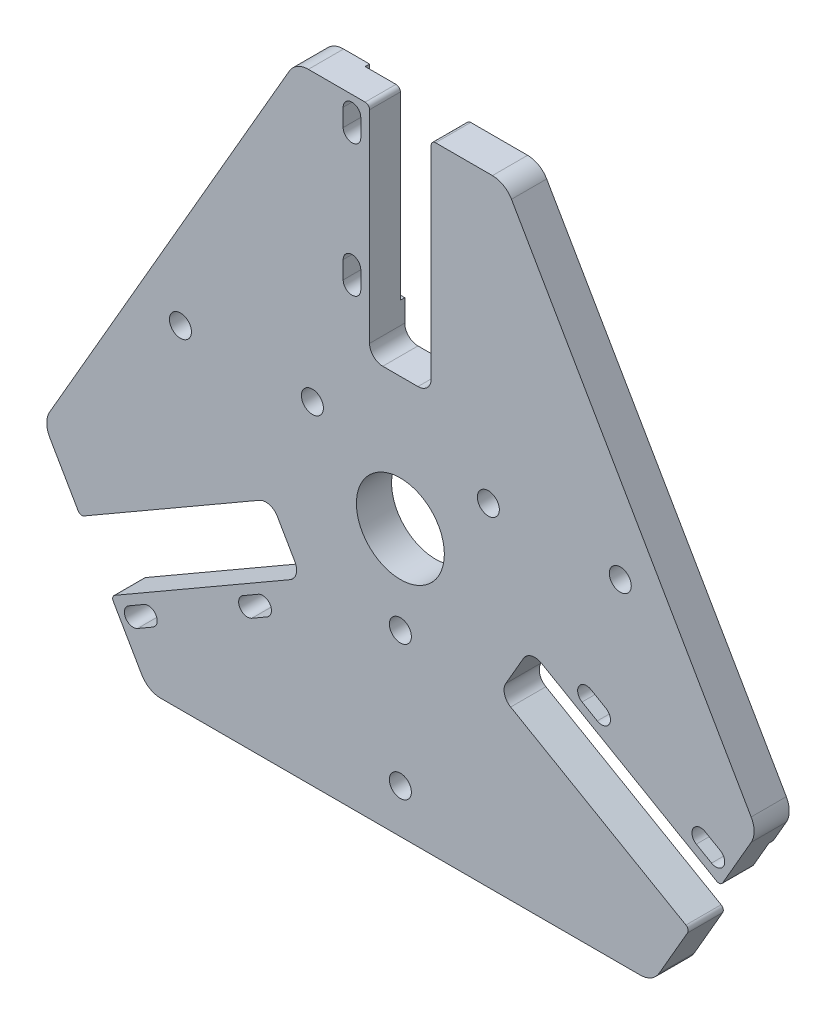
from build123d import *

# Parameters (mm, degrees)
BOSS_EXTRUDE1_DEPTH = 8
SKETCH5_R           = 2.5
SKETCH5_R_2         = 10
CUT_EXTRUDE26_DEPTH = 9
FILLET2_R           = 1
FILLET3_R           = 1
CUT_EXTRUDE27_DEPTH = 1
FILLET4_R           = 1


with BuildPart() as part:
    # Sketch3 → Boss-Extrude1 (new body)
    with BuildSketch(Plane.XY):
        with BuildLine():
            Line((69.282032303, -40), (0, 0))
            Line((0, 0), (-69.282032302, -40))
            Line((-69.282032302, -40), (-58.819418743, -58.121778265))
            ThreePointArc((-58.819418743, -58.121778265), (-56.989291724, -59.951905284), (-54.489291724, -60.621778265))
            Line((-54.489291724, -60.621778265), (54.489291724, -60.621778265))
            ThreePointArc((54.489291724, -60.621778265), (56.989291724, -59.951905284), (58.819418743, -58.121778265))
            Line((58.819418743, -58.121778265), (69.282032303, -40))
        make_face()
        with BuildLine():
            Line((0, 80), (0, 0))
            Line((0, 0), (69.282032303, -40))
            Line((69.282032303, -40), (79.744645862, -21.878221735))
            ThreePointArc((79.744645862, -21.878221735), (80.414518843, -19.378221735), (79.744645862, -16.878221735))
            Line((79.744645862, -16.878221735), (25.255354138, 77.5))
            ThreePointArc((25.255354138, 77.5), (23.425227119, 79.330127019), (20.925227119, 80))
            Line((20.925227119, 80), (0, 80))
        make_face()
        with BuildLine():
            Line((-69.282032302, -40), (0, 0))
            Line((0, 0), (0, 80))
            Line((0, 80), (-20.925227119, 80))
            ThreePointArc((-20.925227119, 80), (-23.425227119, 79.330127019), (-25.255354138, 77.5))
            Line((-25.255354138, 77.5), (-79.744645862, -16.878221735))
            ThreePointArc((-79.744645862, -16.878221735), (-80.414518843, -19.378221735), (-79.744645862, -21.878221735))
            Line((-79.744645862, -21.878221735), (-69.282032302, -40))
        make_face()
    extrude(amount=BOSS_EXTRUDE1_DEPTH)

    # Sketch5 → Cut-Extrude26 (cut, through all)
    with BuildSketch(Plane.XY.offset(8)):
        with BuildLine():
            Line((6.99085892, 80), (-7.00914108, 80))
            Line((-7.00914108, 80), (-7.00914108, 32.993673427))
            ThreePointArc((-7.00914108, 32.993673427), (-6.130461423, 30.872353083), (-4.00914108, 29.993673427))
            Line((-4.00914108, 29.993673427), (3.99085892, 29.993673427))
            ThreePointArc((3.99085892, 29.993673427), (6.112179264, 30.872353083), (6.99085892, 32.993673427))
            Line((6.99085892, 32.993673427), (6.99085892, 80))
        make_face()
        with BuildLine():
            Line((-13.00914108, 76.493673427), (-13.00914108, 72.493673427))
            ThreePointArc((-13.00914108, 72.493673427), (-11.00914108, 70.493673427), (-9.00914108, 72.493673427))
            Line((-9.00914108, 72.493673427), (-9.00914108, 76.493673427))
            ThreePointArc((-9.00914108, 76.493673427), (-11.00914108, 78.493673427), (-13.00914108, 76.493673427))
        make_face()
        with BuildLine():
            Line((-13.00914108, 46.493673427), (-13.00914108, 42.493673427))
            ThreePointArc((-13.00914108, 42.493673427), (-11.00914108, 40.493673427), (-9.00914108, 42.493673427))
            Line((-9.00914108, 42.493673427), (-9.00914108, 46.493673427))
            ThreePointArc((-9.00914108, 46.493673427), (-11.00914108, 48.493673427), (-13.00914108, 46.493673427))
        make_face()
        with Locations((49.99085892, 14.993673427)):
            Circle(SKETCH5_R)
        with Locations((19.99085892, 14.993673427)):
            Circle(SKETCH5_R)
        with Locations((-20.00914108, 14.993673427)):
            Circle(SKETCH5_R)
        with Locations((-50.00914108, 14.993673427)):
            Circle(SKETCH5_R)
        with Locations((-0.00914108, -0.006326573)):
            Circle(SKETCH5_R_2)
        with BuildLine():
            Line((-32.087979405, -10.444148747), (-72.781578086, -33.9386089))
            Line((-72.781578086, -33.9386089), (-65.781578086, -46.062964553))
            Line((-65.781578086, -46.062964553), (-25.087979405, -22.5685044))
            ThreePointArc((-25.087979405, -22.5685044), (-23.690201926, -20.746885324), (-23.989903193, -18.470428188))
            Line((-23.989903193, -18.470428188), (-27.989903193, -11.542224958))
            ThreePointArc((-27.989903193, -11.542224958), (-29.811522269, -10.144447479), (-32.087979405, -10.444148747))
        make_face()
        with BuildLine():
            Line((-33.779322356, -34.514656822), (-30.315220741, -32.514656822))
            ThreePointArc((-30.315220741, -32.514656822), (-29.583169933, -29.782606015), (-32.315220741, -29.050555207))
            Line((-32.315220741, -29.050555207), (-35.779322356, -31.050555207))
            ThreePointArc((-35.779322356, -31.050555207), (-36.511373163, -33.782606015), (-33.779322356, -34.514656822))
        make_face()
        with BuildLine():
            Line((-59.760084469, -49.514656822), (-56.295982854, -47.514656822))
            ThreePointArc((-56.295982854, -47.514656822), (-55.563932046, -44.782606015), (-58.295982854, -44.050555207))
            Line((-58.295982854, -44.050555207), (-61.760084469, -46.050555207))
            ThreePointArc((-61.760084469, -46.050555207), (-62.492135277, -48.782606015), (-59.760084469, -49.514656822))
        make_face()
        with Locations((-0.00914108, -50.628104838)):
            Circle(SKETCH5_R)
        with Locations((-0.00914108, -20.006326573)):
            Circle(SKETCH5_R)
        with BuildLine():
            Line((65.777007546, -46.07088096), (72.777007546, -33.946525307))
            Line((72.777007546, -33.946525307), (32.069697245, -10.444148747))
            ThreePointArc((32.069697245, -10.444148747), (29.793240109, -10.144447479), (27.971621033, -11.542224958))
            Line((27.971621033, -11.542224958), (23.971621033, -18.470428188))
            ThreePointArc((23.971621033, -18.470428188), (23.671919766, -20.746885324), (25.069697245, -22.5685044))
            Line((25.069697245, -22.5685044), (65.777007546, -46.07088096))
        make_face()
        with BuildLine():
            Line((41.296938581, -13.462097939), (44.761040196, -15.462097939))
            ThreePointArc((44.761040196, -15.462097939), (47.493091003, -14.730047132), (46.761040196, -11.997996324))
            Line((46.761040196, -11.997996324), (43.296938581, -9.997996324))
            ThreePointArc((43.296938581, -9.997996324), (40.564887773, -10.730047132), (41.296938581, -13.462097939))
        make_face()
        with BuildLine():
            Line((67.277700694, -28.462097939), (70.741802309, -30.462097939))
            ThreePointArc((70.741802309, -30.462097939), (73.473853117, -29.730047132), (72.741802309, -26.997996324))
            Line((72.741802309, -26.997996324), (69.277700694, -24.997996324))
            ThreePointArc((69.277700694, -24.997996324), (66.545649887, -25.730047132), (67.277700694, -28.462097939))
        make_face()
    extrude(amount=-CUT_EXTRUDE26_DEPTH, mode=Mode.SUBTRACT)

    # Fillet2
    fillet2_edges = [part.edges().sort_by_distance(p)[0] for p in [
        (72.777007546, -33.946525307, 4),
    ]]
    fillet(fillet2_edges, radius=FILLET2_R)

    # Fillet3
    fillet3_edges = [part.edges().sort_by_distance(p)[0] for p in [
        (-65.781578086, -46.062964553, 4),
        (-72.781578086, -33.9386089, 4),
        (65.777007546, -46.07088096, 4),
        (-7.00914108, 80, 4),
        (6.99085892, 80, 4),
    ]]
    fillet(fillet3_edges, radius=FILLET3_R)

    # Sketch7 → Cut-Extrude27 (cut)
    with BuildSketch(Plane(origin=(0, 0, 0), x_dir=(-1, 0, 0), z_dir=(0, 0, -1))):
        with BuildLine():
            Line((61.781578086, -52.991167783), (30.60466355, -34.991167783))
            ThreePointArc((30.60466355, -34.991167783), (24.227648547, -35.182379801), (26.908511127, -29.393091572))
            Line((26.908511127, -29.393091572), (29.408511127, -25.062964553))
            Line((29.408511127, -25.062964553), (65.781578086, -46.062964553))
            Line((65.781578086, -46.062964553), (61.781578086, -52.991167783))
        make_face()
        with BuildLine():
            Line((-76.777007546, -27.018322077), (-45.60009301, -9.018322077))
            ThreePointArc((-45.60009301, -9.018322077), (-42.577179974, -3.400059076), (-38.903940587, -8.616398288))
            Line((-38.903940587, -8.616398288), (-36.403940587, -12.946525307))
            Line((-36.403940587, -12.946525307), (-72.777007546, -33.946525307))
            Line((-72.777007546, -33.946525307), (-76.777007546, -27.018322077))
        make_face()
        with BuildLine():
            Line((15.00914108, 80), (15.00914108, 44))
            ThreePointArc((15.00914108, 44), (18.363243046, 38.572949017), (12.00914108, 38))
            Line((12.00914108, 38), (7.00914108, 38))
            Line((7.00914108, 38), (7.00914108, 80))
            Line((7.00914108, 80), (15.00914108, 80))
        make_face()
    extrude(amount=-CUT_EXTRUDE27_DEPTH, mode=Mode.SUBTRACT)

    # Fillet4
    fillet4_edges = [part.edges().sort_by_distance(p)[0] for p in [
        (45.60009301, -9.018322077, 0.5),
        (-30.60466355, -34.991167783, 0.5),
        (-15.00914108, 44, 0.5),
    ]]
    fillet(fillet4_edges, radius=FILLET4_R)


solid = part.part
